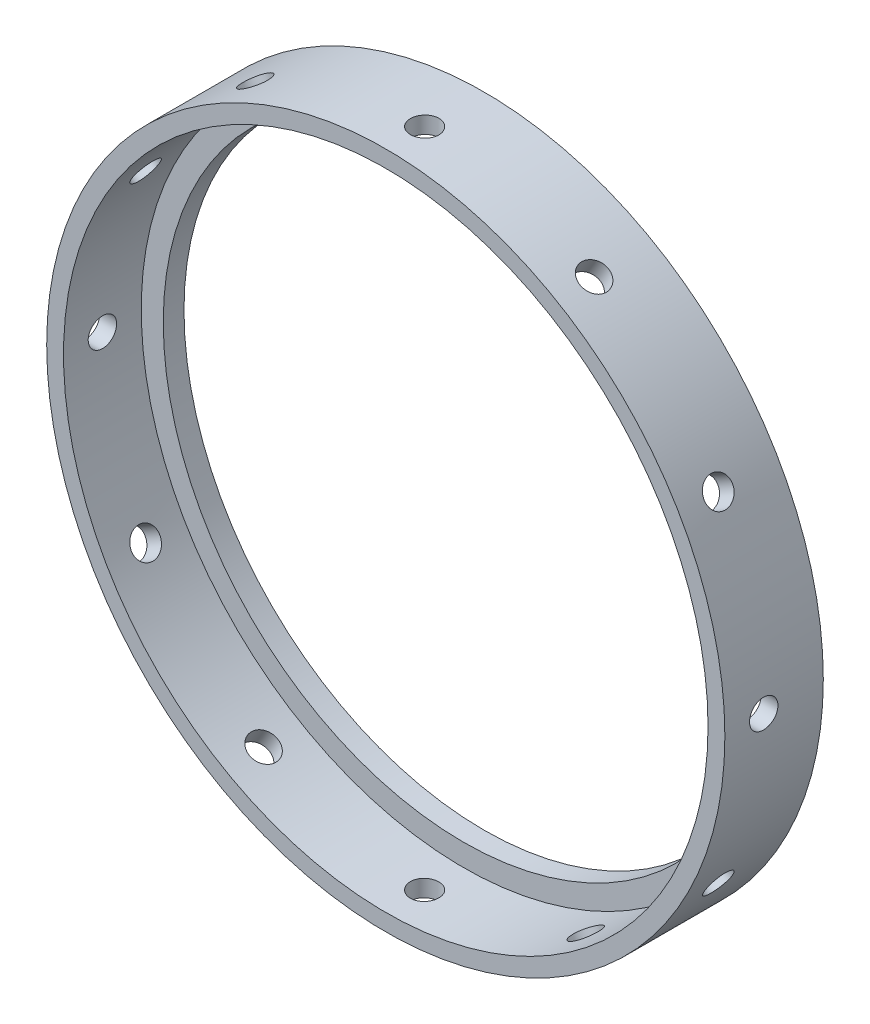
from build123d import *

# Parameters (mm, degrees)
SKETCH1_R           = 83.1215
SKETCH1_R_2         = 78.994
BOSS_EXTRUDE1_DEPTH = 19.05
SKETCH2_R           = 3.478244762
CUT_EXTRUDE1_DEPTH  = 84.1215
CIRPATTERN1_COUNT   = 12
SKETCH3_R           = 83.1215
SKETCH3_R_2         = 73.5965
BOSS_EXTRUDE2_DEPTH = 5.08


with BuildPart() as part:
    # Sketch1 → Boss-Extrude1 (new body)
    with BuildSketch(Plane.XY):
        Circle(SKETCH1_R)
        Circle(SKETCH1_R_2, mode=Mode.SUBTRACT)
    extrude(amount=BOSS_EXTRUDE1_DEPTH)

    # Sketch2 → Cut-Extrude1 (cut, through all)
    with BuildSketch(Plane(origin=(0, 0, 0), x_dir=(1, 0, 0), z_dir=(0, 1, 0))):
        with Locations((0, -9.525)):
            Circle(SKETCH2_R)
    cut_extrude1 = extrude(amount=-CUT_EXTRUDE1_DEPTH, mode=Mode.SUBTRACT)

    # CirPattern1: Cut-Extrude1 ×12 about axis
    cirpattern1_axis = Axis((0, 0, 2.080715754), (0, 0, 1))
    for i in range(1, CIRPATTERN1_COUNT):
        add(cut_extrude1.rotate(cirpattern1_axis, i * 360 / CIRPATTERN1_COUNT), mode=Mode.SUBTRACT)

    # Sketch3 → Boss-Extrude2 (add)
    with BuildSketch(Plane(origin=(0, 0, 0), x_dir=(-1, 0, 0), z_dir=(0, 0, -1))):
        Circle(SKETCH3_R)
        Circle(SKETCH3_R_2, mode=Mode.SUBTRACT)
    extrude(amount=BOSS_EXTRUDE2_DEPTH)


solid = part.part
